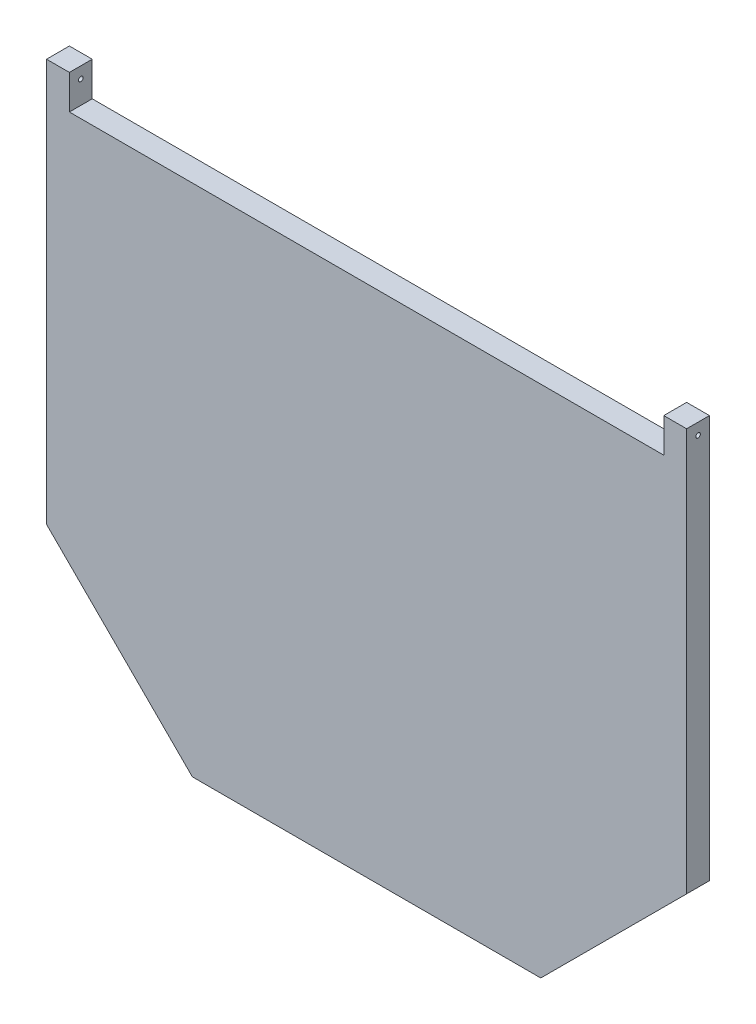
from build123d import *

# Parameters (mm, degrees)
BOSS_EXTRUDE1_DEPTH = 12.7
SKETCH2_W           = 330.2
SKETCH2_H           = 19.05
CUT_EXTRUDE1_DEPTH  = 13.7
SKETCH3_R           = 1.27
CUT_EXTRUDE2_DEPTH  = 356.6
CUT_EXTRUDE7_DEPTH  = 6.35


with BuildPart() as part:
    # Sketch1 → Boss-Extrude1 (new body)
    with BuildSketch(Plane.XY):
        Polygon((0, 0), (355.6, 0), (355.6, -223.774), (274.574, -304.751813258), (81.026, -304.751813258), (0, -223.774), align=None)
    extrude(amount=BOSS_EXTRUDE1_DEPTH)

    # Sketch2 → Cut-Extrude1 (cut, through all)
    with BuildSketch(Plane.XY.offset(12.7)):
        with Locations((177.8, -9.525)):
            Rectangle(SKETCH2_W, SKETCH2_H)
    extrude(amount=-CUT_EXTRUDE1_DEPTH, mode=Mode.SUBTRACT)

    # Sketch3 → Cut-Extrude2 (cut, through all)
    with BuildSketch(Plane.ZY):
        with Locations((6.35, -6.35)):
            Circle(SKETCH3_R)
    extrude(amount=-CUT_EXTRUDE2_DEPTH, mode=Mode.SUBTRACT)

    # Sketch4 → Cut-Extrude7 (cut)
    with BuildSketch(Plane.XY):
        Polygon((10.3378, -45.974), (10.3378, -219.490141692), (85.306255844, -294.414013258), (86.209906071, -292.23149061), (12.520322648, -218.58573091), (12.520322648, -45.974), align=None)
        Polygon((270.293744156, -294.414013258), (345.2622, -219.490141692), (345.2622, -45.974), (342.9, -45.974), (342.9, -218.511274805), (269.416328936, -292.294854171), align=None)
    extrude(amount=CUT_EXTRUDE7_DEPTH, mode=Mode.SUBTRACT)


solid = part.part
